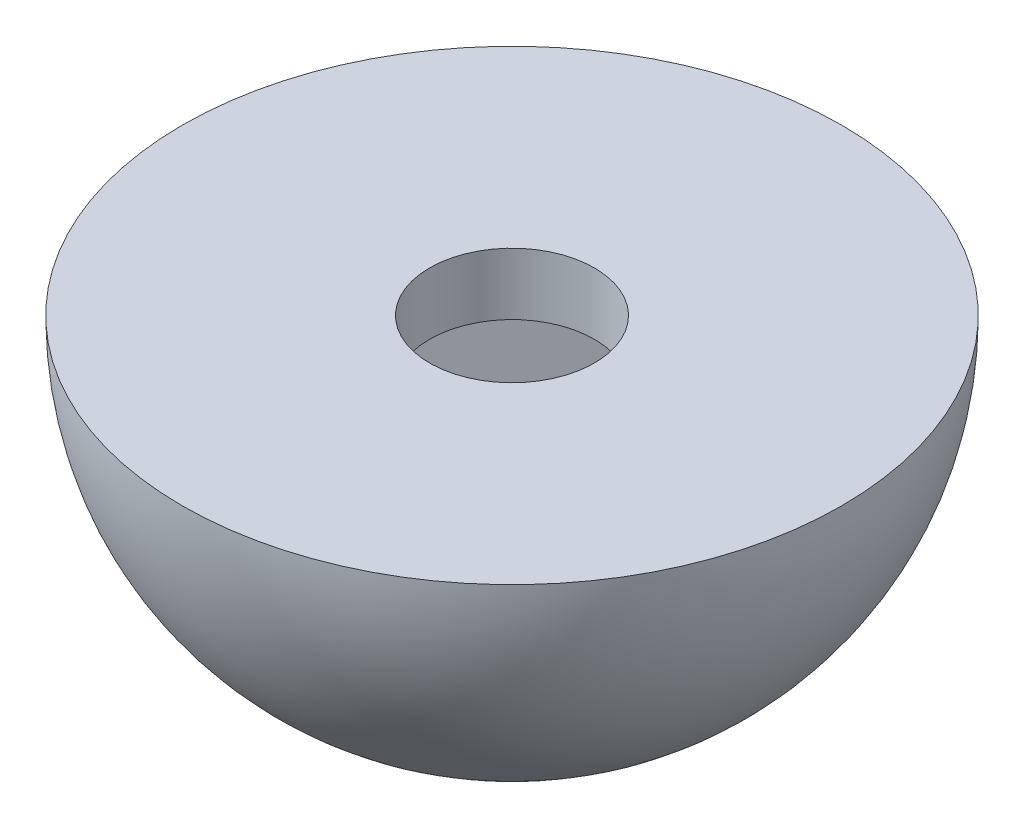
from build123d import *

# Parameters (mm, degrees)
ESQUISSE2_R                  = 1
ENL_V_MAT_EXTRU_1_DEPTH      = 5
ENL_V_MAT_EXTRU_3_DEPTH      = 2.25
ENL_V_MAT_EXTRU_3_DEPTH_BACK = 1.872983346


with BuildPart() as part:
    # Esquisse1 → Révolution1 (revolve)
    with BuildSketch(Plane.XY):
        with BuildLine():
            Line((-4, 0), (0, 0))
            Line((0, 0), (0, -4))
            ThreePointArc((0, -4), (-2.828427125, -2.828427125), (-4, 0))
        make_face()
    revolve(axis=Axis((0, 0, 0), (0, -1, 0)))

    # Esquisse2 → Enlèv. mat.-Extru.1 (cut, through all)
    with BuildSketch(Plane(origin=(0, 0, 0), x_dir=(1, 0, 0), z_dir=(0, 1, 0))):
        with Locations(Location((0, 0, 0), (0, 0, 180))):  # turned: the seam where the file's is
            Circle(ESQUISSE2_R)
    extrude(amount=-ENL_V_MAT_EXTRU_1_DEPTH, mode=Mode.SUBTRACT)

    # Esquisse4 → Enlèv. mat.-Extru.3 (cut, two sides)
    with BuildSketch(Plane(origin=(0, -3, 0), x_dir=(1, 0, 0), z_dir=(0, 1, 0))) as enl_v_mat_extru_3_sk:
        Polygon((2.16733828, -0.855303911), (1.824384055, 1.449318053), (-0.342954225, 2.304621965), (-2.16733828, 0.855303911), (-1.824384055, -1.449318053), (0.342954225, -2.304621965), align=None)
    extrude(amount=ENL_V_MAT_EXTRU_3_DEPTH, mode=Mode.SUBTRACT)
    extrude(enl_v_mat_extru_3_sk.sketch, amount=-ENL_V_MAT_EXTRU_3_DEPTH_BACK, mode=Mode.SUBTRACT)


solid = part.part
